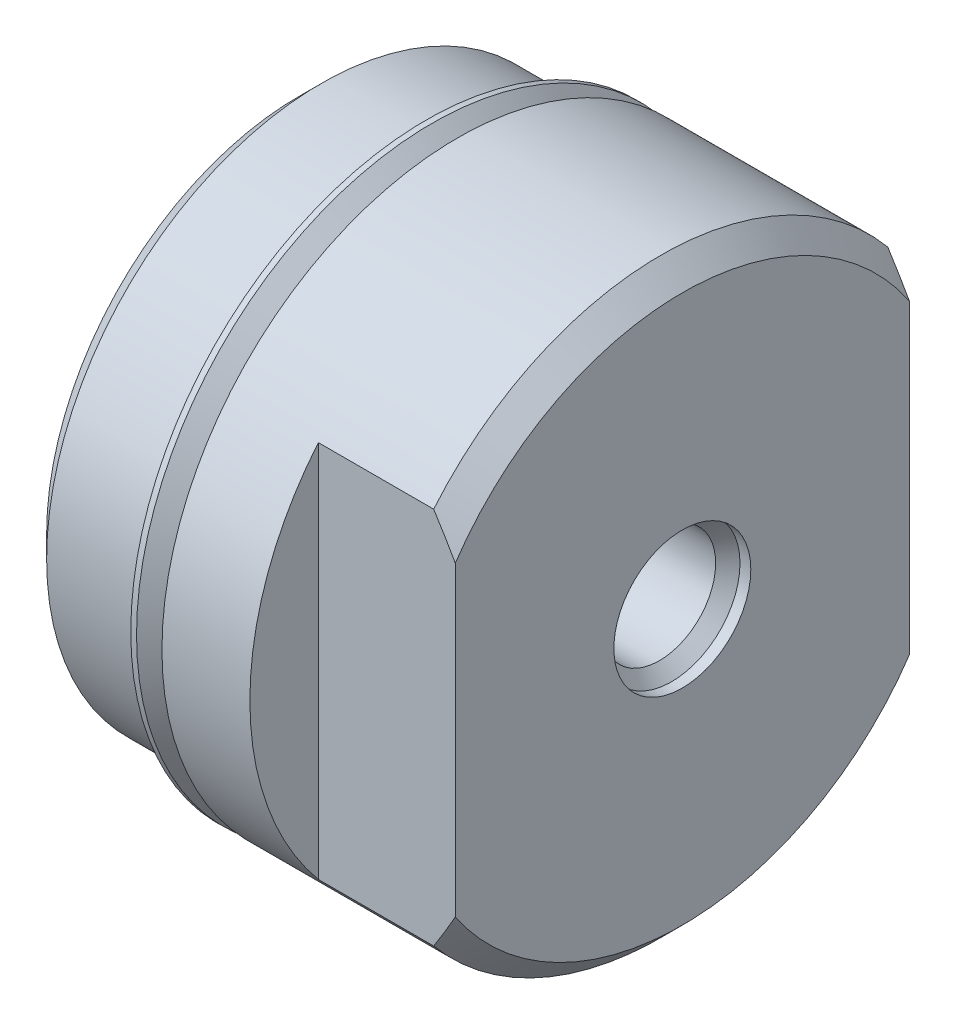
from build123d import *

# Parameters (mm, degrees)
SKETCH2_W          = 32.004
SKETCH2_H          = 83.312
SKETCH2_W_2        = 16.002
SKETCH2_H_2        = 41.656
CUT_EXTRUDE1_DEPTH = 4.826


with BuildPart() as part:
    # Sketch1 → Revolve1 (revolve)
    with BuildSketch(Plane.XY):
        Polygon((0, 0), (0, 8.9154), (0.762, 9.6774), (4.0386, 9.6774), (4.8006, 8.9154), (5.5626, 8.9154), (5.5626, 10.414), (12.7254, 10.414), (13.4874, 9.652), (13.4874, 0), align=None)
    revolve(axis=Axis((13.4874, 0, 0), (-1, 0, 0)))

    # Sketch2 → Cut-Extrude1 (cut)
    with BuildSketch(Plane(origin=(13.4874, 0, 0), x_dir=(0, 0, -1), z_dir=(1, 0, 0))):
        Rectangle(SKETCH2_W, SKETCH2_H)
        Rectangle(SKETCH2_W_2, SKETCH2_H_2, mode=Mode.SUBTRACT)
    extrude(amount=-CUT_EXTRUDE1_DEPTH, mode=Mode.SUBTRACT)

    # Sketch3 → Hole1 (revolve, cut)
    with BuildSketch(Plane.ZX):
        Polygon((0, 0), (0, 6.35), (6.35, 6.35), (6.35, 0.254), (6.604, 0), align=None)
    revolve(axis=Axis((-6.445314094, 0, 0), (1, 0, 0)), mode=Mode.SUBTRACT)

    # Sketch5 → Hole2 (revolve, cut)
    with BuildSketch(Plane(origin=(13.4874, 0, 0), x_dir=(0, 0, -1), z_dir=(0, 1, 0))):
        Polygon((0, 0), (0, 13.8684), (1.98374, 13.8684), (1.98374, 0.81026), (2.413, 0.381), (2.413, 0), align=None)
    revolve(axis=Axis((19.617423899, 0, 0), (-1, 0, 0)), mode=Mode.SUBTRACT)

    # Sketch7 → Revolve2 (revolve)
    with BuildSketch(Plane.XY):
        Polygon((4.46379893, 10.329831804), (5.878230735, 8.9154), (6.16559893, 8.9154), (4.66699893, 10.414), (4.46379893, 10.414), align=None)
    revolve(axis=Axis((13.4874, 0, 0), (-1, 0, 0)))


solid = part.part
